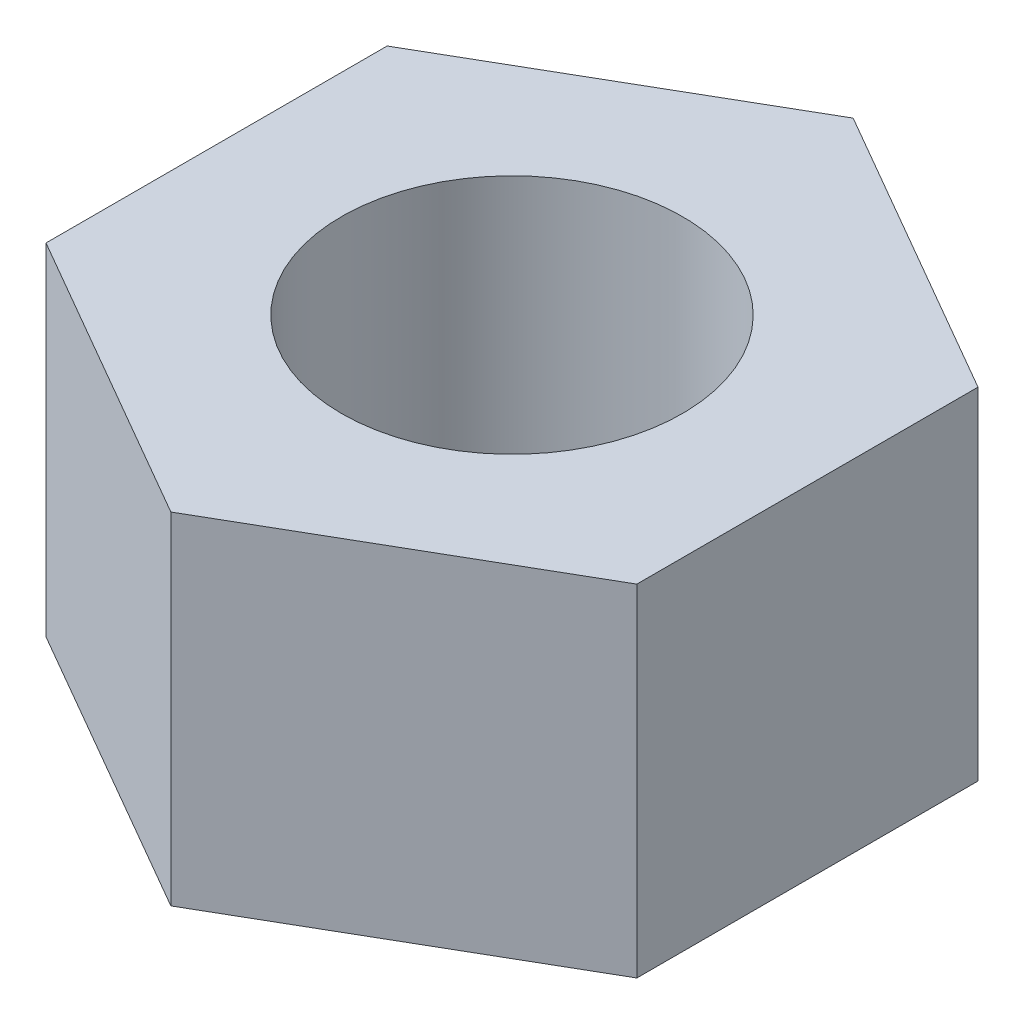
from build123d import *

# Parameters (mm, degrees)
BOSS_EXTRUDE1_DEPTH = 9
SKETCH2_R           = 4.5
CUT_EXTRUDE1_DEPTH  = 9


with BuildPart() as part:
    # Sketch1 → Boss-Extrude1 (new body)
    with BuildSketch(Plane(origin=(0, 0, 0), x_dir=(1, 0, 0), z_dir=(0, 1, 0))):
        Polygon((0, 9), (-7.794228634, 4.5), (-7.794228634, -4.5), (0, -9), (7.794228634, -4.5), (7.794228634, 4.5), align=None)
    extrude(amount=BOSS_EXTRUDE1_DEPTH)

    # Sketch2 → Cut-Extrude1 (cut)
    with BuildSketch(Plane(origin=(0, 9, 0), x_dir=(1, 0, 0), z_dir=(0, 1, 0))):
        with Locations(Location((0, 0, 0), (0, 0, 270))):  # turned: the seam where the file's is
            Circle(SKETCH2_R)
    extrude(amount=-CUT_EXTRUDE1_DEPTH, mode=Mode.SUBTRACT)


solid = part.part
